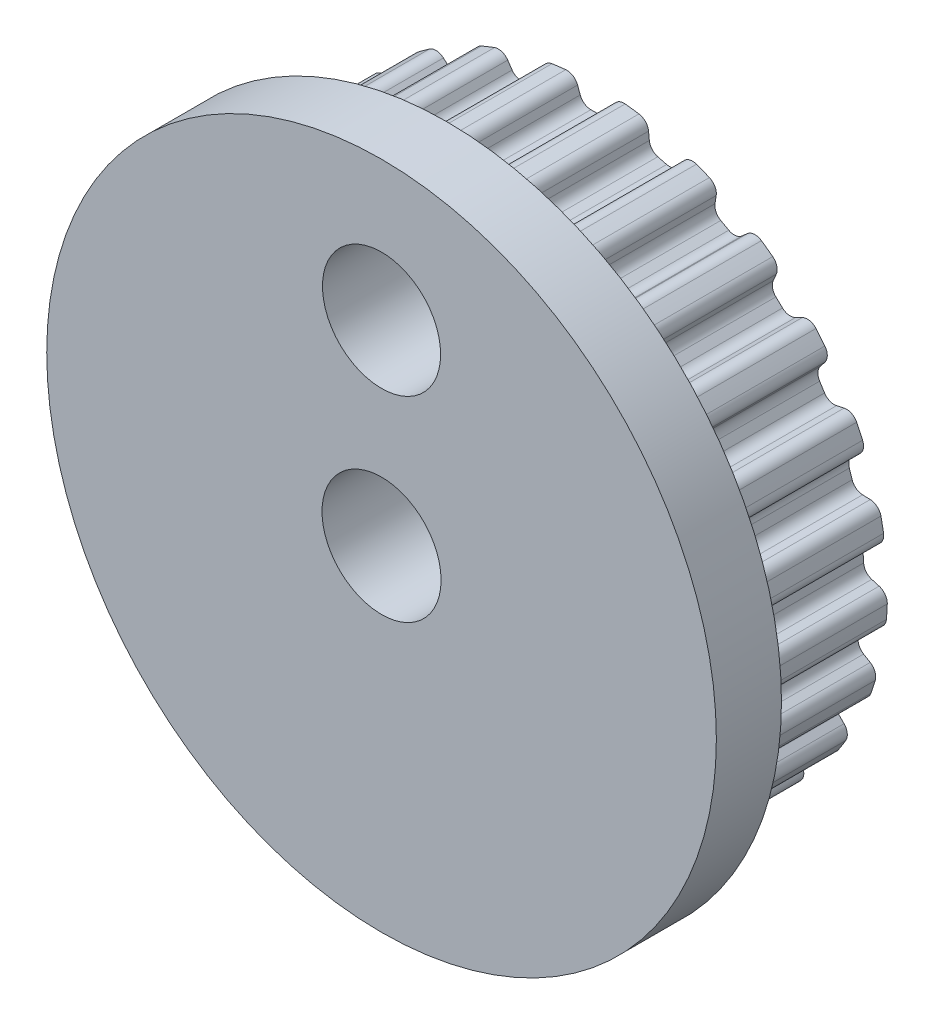
from build123d import *

# Parameters (mm, degrees)
BOSS_EXTRUDE1_DEPTH = 4.000000001
SKETCH2_R           = 9
BOSS_EXTRUDE2_DEPTH = 1.75
SKETCH4_W           = 4.5
SKETCH4_H           = 4.5
BOSS_EXTRUDE3_DEPTH = 1.75
SKETCH3_R           = 1.6
CUT_EXTRUDE2_DEPTH  = 8.500000001
SKETCH5_R           = 1.5875
CUT_EXTRUDE3_DEPTH  = 8.500000001


with BuildPart() as part:
    # Sketch1 → Boss-Extrude1 (new body)
    with BuildSketch(Plane(origin=(0, 0, -5.299999992), x_dir=(-1, 0, 0), z_dir=(0, 0, -1))):
        with BuildLine():
            Line((-2.770498963, -6.663011251), (-2.541538281, -6.753663208))
            ThreePointArc((-2.541538281, -6.753663208), (-2.399281022, -6.869272551), (-2.349061487, -7.04556959))
            Line((-2.349061487, -7.04556959), (-2.354850369, -7.252814955))
            ThreePointArc((-2.354850369, -7.252814955), (-2.295763451, -7.44184279), (-2.13298896, -7.55465791))
            ThreePointArc((-2.13298896, -7.55465791), (-1.9522156, -7.60337769), (-1.770331764, -7.647772452))
            ThreePointArc((-1.770331764, -7.647772452), (-1.573342284, -7.627329016), (-1.430499165, -7.490147994))
            Line((-1.430499165, -7.490147994), (-1.335730789, -7.305748684))
            ThreePointArc((-1.335730789, -7.305748684), (-1.206791332, -7.175451857), (-1.026435123, -7.142675578))
            Line((-1.026435123, -7.142675578), (-0.782123427, -7.173539321))
            ThreePointArc((-0.782123427, -7.173539321), (-0.615584572, -7.250138629), (-0.523099481, -7.408407869))
            Line((-0.523099481, -7.408407869), (-0.477166643, -7.610581923))
            ThreePointArc((-0.477166643, -7.610581923), (-0.372926733, -7.778976773), (-0.187210126, -7.847767225))
            ThreePointArc((-0.187210126, -7.847767225), (1.8e-08, -7.849999876), (0.187210163, -7.847767225))
            ThreePointArc((0.187210163, -7.847767225), (0.372926769, -7.778976773), (0.477166678, -7.610581924))
            Line((0.477166678, -7.610581924), (0.523099513, -7.408407881))
            ThreePointArc((0.523099513, -7.408407881), (0.615584602, -7.250138644), (0.782123452, -7.173539334))
            Line((0.782123452, -7.173539334), (1.026435157, -7.142675586))
            ThreePointArc((1.026435157, -7.142675586), (1.206791369, -7.175451863), (1.33573083, -7.305748691))
            Line((1.33573083, -7.305748691), (1.430499202, -7.490147994))
            ThreePointArc((1.430499202, -7.490147994), (1.573342321, -7.627329016), (1.770331801, -7.647772452))
            ThreePointArc((1.770331801, -7.647772452), (1.952215637, -7.60337769), (2.132988997, -7.55465791))
            ThreePointArc((2.132988997, -7.55465791), (2.295763494, -7.441842782), (2.354850406, -7.252814935))
            Line((2.354850406, -7.252814935), (2.349061514, -7.045569606))
            ThreePointArc((2.349061514, -7.045569606), (2.399281043, -6.869272556), (2.541538305, -6.753663204))
            Line((2.541538305, -6.753663204), (2.770498989, -6.663011244))
            ThreePointArc((2.770498989, -6.663011244), (2.953340111, -6.64990502), (3.11063221, -6.744042389))
            Line((3.11063221, -6.744042389), (3.248281539, -6.899080544))
            ThreePointArc((3.248281539, -6.899080544), (3.42075251, -6.996428125), (3.616637274, -6.967240001))
            ThreePointArc((3.616637274, -6.967240001), (3.781766365, -6.879007311), (3.94474428, -6.786861647))
            ThreePointArc((3.94474428, -6.786861647), (4.074348937, -6.637110438), (4.084570207, -6.439326927))
            Line((4.084570207, -6.439326927), (4.027423359, -6.240032231))
            ThreePointArc((4.027423359, -6.240032231), (4.032221853, -6.056784784), (4.141258967, -5.909429568))
            Line((4.141258967, -5.909429568), (4.340482222, -5.76468539))
            ThreePointArc((4.340482222, -5.76468539), (4.514319692, -5.706520185), (4.690081199, -5.758583127))
            Line((4.690081199, -5.758583127), (4.861962355, -5.874518455))
            ThreePointArc((4.861962355, -5.874518455), (5.053224205, -5.925915922), (5.235696117, -5.848930236))
            ThreePointArc((5.235696117, -5.848930236), (5.373694804, -5.722403597), (5.50863678, -5.592621893))
            ThreePointArc((5.50863678, -5.592621893), (5.596928058, -5.415344021), (5.557641445, -5.221232311))
            Line((5.557641445, -5.221232311), (5.452727407, -5.042410696))
            ThreePointArc((5.452727407, -5.042410696), (5.411803358, -4.863726966), (5.480769122, -4.693884755))
            Line((5.480769122, -4.693884755), (5.637737001, -4.504143178))
            ThreePointArc((5.637737001, -4.504143178), (5.791647936, -4.404573728), (5.974835084, -4.411290898))
            Line((5.974835084, -4.411290898), (6.170148257, -4.480838795))
            ThreePointArc((6.170148257, -4.480838795), (6.368183279, -4.483056618), (6.525776925, -4.363110665))
            ThreePointArc((6.525776925, -4.363110665), (6.627974228, -4.206240225), (6.726401351, -4.046977156))
            ThreePointArc((6.726401351, -4.046977156), (6.767831585, -3.853311658), (6.681505632, -3.675068511))
            Line((6.681505632, -3.675068511), (6.535416505, -3.527955909))
            ThreePointArc((6.535416505, -3.527955909), (6.451341341, -3.365063263), (6.475902375, -3.183405886))
            Line((6.475902375, -3.183405886), (6.580751989, -2.960589078))
            ThreePointArc((6.580751989, -2.960589078), (6.705065617, -2.825871679), (6.884168106, -2.78682102))
            Line((6.884168106, -2.78682102), (7.090641024, -2.805611531))
            ThreePointArc((7.090641024, -2.805611531), (7.283005966, -2.758510368), (7.405819176, -2.603140787))
            ThreePointArc((7.405819176, -2.603140787), (7.46579367, -2.425783284), (7.52152141, -2.247045927))
            ThreePointArc((7.52152141, -2.247045927), (7.513487384, -2.049161499), (7.385546242, -1.897986579))
            Line((7.385546242, -1.897986579), (7.207461372, -1.791826697))
            ThreePointArc((7.207461372, -1.791826697), (7.085517816, -1.654960251), (7.06413088, -1.472901871))
            Line((7.06413088, -1.472901871), (7.110274201, -1.231010202))
            ThreePointArc((7.110274201, -1.231010202), (7.197179435, -1.069609688), (7.360943563, -0.987244916))
            Line((7.360943563, -0.987244916), (7.565602753, -0.95409736))
            ThreePointArc((7.565602753, -0.95409736), (7.740210608, -0.86063675), (7.820526569, -0.679605993))
            ThreePointArc((7.820526569, -0.679605993), (7.834509837, -0.492905448), (7.844036614, -0.305924525))
            ThreePointArc((7.844036614, -0.305924525), (7.78704314, -0.116254991), (7.625525841, -0.001647178))
            Line((7.625525841, -0.001647178), (7.426634918, 0.056889606))
            ThreePointArc((7.426634918, 0.056889606), (7.274485151, 0.15913001), (7.208494045, 0.330149967))
            Line((7.208494045, 0.330149967), (7.193031666, 0.575917525))
            ThreePointArc((7.193031666, 0.575917525), (7.237067931, 0.753859804), (7.375203825, 0.874363422))
            Line((7.375203825, 0.874363422), (7.565189822, 0.957366261))
            ThreePointArc((7.565189822, 0.957366261), (7.711069345, 1.091313843), (7.743841513, 1.286630957))
            ThreePointArc((7.743841513, 1.286630957), (7.710954935, 1.470943449), (7.673682148, 1.654419227))
            ThreePointArc((7.673682148, 1.654419227), (7.571310327, 1.82395625), (7.386365577, 1.894795725))
            Line((7.386365577, 1.894795725), (7.179165715, 1.902031296))
            ThreePointArc((7.179165715, 1.902031296), (7.006369859, 1.963221511), (6.899921047, 2.112457233))
            Line((6.899921047, 2.112457233), (6.823824527, 2.346658216))
            ThreePointArc((6.823824527, 2.346658216), (6.822224861, 2.529961496), (6.926052937, 2.681032281))
            Line((6.926052937, 2.681032281), (7.089428199, 2.808675019))
            ThreePointArc((7.089428199, 2.808675019), (7.197413244, 2.974693155), (7.180582424, 3.172024133))
            ThreePointArc((7.180582424, 3.172024133), (7.10289238, 3.342367562), (7.02116201, 3.510809758))
            ThreePointArc((7.02116201, 3.510809758), (6.879844249, 3.649561624), (6.683092823, 3.67218166))
            Line((6.683092823, 3.67218166), (6.480603082, 3.627661399))
            ThreePointArc((6.480603082, 3.627661399), (6.298018541, 3.643956633), (6.157800604, 3.762031099))
            Line((6.157800604, 3.762031099), (6.025851382, 3.969949803))
            ThreePointArc((6.025851382, 3.969949803), (5.978716304, 4.147096461), (6.041712663, 4.319242076))
            Line((6.041712663, 4.319242076), (6.168211718, 4.483504424))
            ThreePointArc((6.168211718, 4.483504424), (6.231517191, 4.671161588), (6.166140924, 4.858107403))
            ThreePointArc((6.166140924, 4.858107403), (6.048528974, 5.003778443), (5.927476451, 5.146603192))
            ThreePointArc((5.927476451, 5.146603192), (5.756092274, 5.245851614), (5.559896791, 5.218830927))
            Line((5.559896791, 5.218830927), (5.374840317, 5.125352196))
            ThreePointArc((5.374840317, 5.125352196), (5.193939557, 5.095728573), (5.028762915, 5.175222731))
            Line((5.028762915, 5.175222731), (4.849251859, 5.343794843))
            ThreePointArc((4.849251859, 5.343794843), (4.759543042, 5.50365408), (4.777749369, 5.686057966))
            Line((4.777749369, 5.686057966), (4.859423838, 5.876618788))
            ThreePointArc((4.859423838, 5.876618788), (4.874072, 6.074123776), (4.764258119, 6.238937914))
            ThreePointArc((4.764258119, 6.238937914), (4.614114251, 6.350783528), (4.461345743, 6.459016637))
            ThreePointArc((4.461345743, 6.459016637), (4.270663826, 6.512525475), (4.087351951, 6.437561846))
            Line((4.087351951, 6.437561846), (3.931356637, 6.300998273))
            ThreePointArc((3.931356637, 6.300998273), (3.763506296, 6.227317127), (3.583749576, 6.263236065))
            Line((3.583749576, 6.263236065), (3.367956, 6.381869588))
            ThreePointArc((3.367956, 6.381869588), (3.241310171, 6.514396877), (3.213582509, 6.69559794))
            Line((3.213582509, 6.69559794), (3.245300476, 6.900483573))
            ThreePointArc((3.245300476, 6.900483573), (3.210370947, 7.095426422), (3.063019466, 7.227753016))
            ThreePointArc((3.063019466, 7.227753016), (2.889777761, 7.298745536), (2.714892269, 7.365586324))
            ThreePointArc((2.714892269, 7.365586324), (2.516893872, 7.369993419), (2.357983776, 7.251797104))
            Line((2.357983776, 7.251797104), (2.240851316, 7.080729469))
            ThreePointArc((2.240851316, 7.080729469), (2.096598059, 6.967620471), (1.913556053, 6.957707268))
            Line((1.913556053, 6.957707268), (1.675039076, 7.018948014))
            ThreePointArc((1.675039076, 7.018948014), (1.51941385, 7.115816183), (1.447494432, 7.284428907))
            Line((1.447494432, 7.284428907), (1.427262951, 7.490765576))
            ThreePointArc((1.427262951, 7.490765576), (1.344950483, 7.670897333), (1.169320022, 7.762421829))
            ThreePointArc((1.169320022, 7.762421829), (0.983865903, 7.788100529), (0.797852133, 7.809349137))
            ThreePointArc((0.797852133, 7.809349137), (0.604978216, 7.764377573), (0.480454802, 7.610375273))
            Line((0.480454802, 7.610375273), (0.409545077, 7.415552396))
            ThreePointArc((0.409545077, 7.415552396), (0.297952865, 7.270122591), (0.123126767, 7.215000134))
            Line((0.123126767, 7.215000134), (-0.12312673, 7.215000134))
            ThreePointArc((-0.12312673, 7.215000134), (-0.297952827, 7.270122591), (-0.409545038, 7.415552395))
            Line((-0.409545038, 7.415552395), (-0.480454763, 7.610375271))
            ThreePointArc((-0.480454763, 7.610375271), (-0.604978178, 7.764377573), (-0.797852096, 7.809349137))
            ThreePointArc((-0.797852096, 7.809349137), (-0.983865866, 7.788100529), (-1.169319985, 7.762421829))
            ThreePointArc((-1.169319985, 7.762421829), (-1.344950446, 7.670897333), (-1.427262914, 7.490765576))
            Line((-1.427262914, 7.490765576), (-1.447494396, 7.284428898))
            ThreePointArc((-1.447494396, 7.284428898), (-1.519413814, 7.115816175), (-1.67503904, 7.018948005))
            Line((-1.67503904, 7.018948005), (-1.913556012, 6.957707261))
            ThreePointArc((-1.913556012, 6.957707261), (-2.096598018, 6.967620464), (-2.240851274, 7.080729462))
            Line((-2.240851274, 7.080729462), (-2.357983739, 7.251797104))
            ThreePointArc((-2.357983739, 7.251797104), (-2.516893836, 7.369993419), (-2.714892233, 7.365586324))
            ThreePointArc((-2.714892233, 7.365586324), (-2.889777725, 7.298745536), (-3.063019429, 7.227753016))
            ThreePointArc((-3.063019429, 7.227753016), (-3.210370911, 7.095426422), (-3.24530044, 6.900483573))
            Line((-3.24530044, 6.900483573), (-3.21358247, 6.695597928))
            ThreePointArc((-3.21358247, 6.695597928), (-3.241310132, 6.514396865), (-3.367955962, 6.381869576))
            Line((-3.367955962, 6.381869576), (-3.58374953, 6.263236057))
            ThreePointArc((-3.58374953, 6.263236057), (-3.76350625, 6.227317119), (-3.931356591, 6.300998266))
            Line((-3.931356591, 6.300998266), (-4.087351915, 6.437561846))
            ThreePointArc((-4.087351915, 6.437561846), (-4.27066379, 6.512525475), (-4.461345707, 6.459016637))
            ThreePointArc((-4.461345707, 6.459016637), (-4.614114214, 6.350783528), (-4.764258082, 6.238937914))
            ThreePointArc((-4.764258082, 6.238937914), (-4.874071964, 6.074123776), (-4.859423801, 5.876618788))
            Line((-4.859423801, 5.876618788), (-4.77774934, 5.686057982))
            ThreePointArc((-4.77774934, 5.686057982), (-4.759543013, 5.503654097), (-4.849251829, 5.343794859))
            Line((-4.849251829, 5.343794859), (-5.028762894, 5.17522274))
            ThreePointArc((-5.028762894, 5.17522274), (-5.193939536, 5.095728582), (-5.374840296, 5.125352204))
            Line((-5.374840296, 5.125352204), (-5.559896754, 5.218830927))
            ThreePointArc((-5.559896754, 5.218830927), (-5.756092237, 5.245851614), (-5.927476414, 5.146603192))
            ThreePointArc((-5.927476414, 5.146603192), (-6.048528938, 5.003778443), (-6.166140887, 4.858107403))
            ThreePointArc((-6.166140887, 4.858107403), (-6.231517154, 4.671161588), (-6.168211682, 4.483504424))
            Line((-6.168211682, 4.483504424), (-6.04171263, 4.31924208))
            ThreePointArc((-6.04171263, 4.31924208), (-5.978716271, 4.147096465), (-6.025851349, 3.969949807))
            Line((-6.025851349, 3.969949807), (-6.157800573, 3.7620311))
            ThreePointArc((-6.157800573, 3.7620311), (-6.29801851, 3.643956634), (-6.480603051, 3.6276614))
            Line((-6.480603051, 3.6276614), (-6.683092787, 3.67218166))
            ThreePointArc((-6.683092787, 3.67218166), (-6.879844213, 3.649561624), (-7.021161973, 3.510809758))
            ThreePointArc((-7.021161973, 3.510809758), (-7.102892344, 3.342367562), (-7.180582387, 3.172024133))
            ThreePointArc((-7.180582387, 3.172024133), (-7.197413207, 2.974693155), (-7.089428162, 2.808675019))
            Line((-7.089428162, 2.808675019), (-6.926052897, 2.681032278))
            ThreePointArc((-6.926052897, 2.681032278), (-6.822224821, 2.529961494), (-6.823824488, 2.346658214))
            Line((-6.823824488, 2.346658214), (-6.899921006, 2.112457233))
            ThreePointArc((-6.899921006, 2.112457233), (-7.006369819, 1.963221511), (-7.179165675, 1.902031296))
            Line((-7.179165675, 1.902031296), (-7.386365541, 1.894795725))
            ThreePointArc((-7.386365541, 1.894795725), (-7.571310291, 1.82395625), (-7.673682111, 1.654419227))
            ThreePointArc((-7.673682111, 1.654419227), (-7.710954911, 1.470943384), (-7.743841498, 1.286630826))
            ThreePointArc((-7.743841498, 1.286630826), (-7.711069328, 1.091313715), (-7.565189806, 0.957366136))
            Line((-7.565189806, 0.957366136), (-7.375203809, 0.874363296))
            ThreePointArc((-7.375203809, 0.874363296), (-7.237067915, 0.753859678), (-7.19303165, 0.5759174))
            Line((-7.19303165, 0.5759174), (-7.20849403, 0.330149843))
            ThreePointArc((-7.20849403, 0.330149843), (-7.274485135, 0.159129886), (-7.426634903, 0.056889483))
            Line((-7.426634903, 0.056889483), (-7.6255258, -0.001647294))
            ThreePointArc((-7.6255258, -0.001647294), (-7.7870431, -0.116255109), (-7.844036572, -0.305924646))
            ThreePointArc((-7.844036572, -0.305924646), (-7.834509796, -0.492905509), (-7.820526532, -0.679605993))
            ThreePointArc((-7.820526532, -0.679605993), (-7.740210572, -0.86063675), (-7.565602716, -0.95409736))
            Line((-7.565602716, -0.95409736), (-7.360943526, -0.987244916))
            ThreePointArc((-7.360943526, -0.987244916), (-7.197179397, -1.069609688), (-7.110274163, -1.231010202))
            Line((-7.110274163, -1.231010202), (-7.064130842, -1.47290187))
            ThreePointArc((-7.064130842, -1.47290187), (-7.085517778, -1.654960251), (-7.207461334, -1.791826697))
            Line((-7.207461334, -1.791826697), (-7.385546205, -1.897986579))
            ThreePointArc((-7.385546205, -1.897986579), (-7.513487347, -2.049161499), (-7.521521373, -2.247045927))
            ThreePointArc((-7.521521373, -2.247045927), (-7.465793634, -2.425783284), (-7.405819139, -2.603140787))
            ThreePointArc((-7.405819139, -2.603140787), (-7.28300593, -2.758510368), (-7.090640987, -2.805611531))
            Line((-7.090640987, -2.805611531), (-6.884168079, -2.786821021))
            ThreePointArc((-6.884168079, -2.786821021), (-6.705065589, -2.82587168), (-6.580751962, -2.960589079))
            Line((-6.580751962, -2.960589079), (-6.475902344, -3.183405892))
            ThreePointArc((-6.475902344, -3.183405892), (-6.451341311, -3.36506327), (-6.535416475, -3.527955915))
            Line((-6.535416475, -3.527955915), (-6.681505595, -3.675068511))
            ThreePointArc((-6.681505595, -3.675068511), (-6.767831549, -3.853311658), (-6.726401314, -4.046977156))
            ThreePointArc((-6.726401314, -4.046977156), (-6.627974191, -4.206240225), (-6.525776888, -4.363110665))
            ThreePointArc((-6.525776888, -4.363110665), (-6.368183242, -4.483056618), (-6.17014822, -4.480838795))
            Line((-6.17014822, -4.480838795), (-5.974835047, -4.411290898))
            ThreePointArc((-5.974835047, -4.411290898), (-5.791647899, -4.404573728), (-5.637736963, -4.504143178))
            Line((-5.637736963, -4.504143178), (-5.480769085, -4.693884754))
            ThreePointArc((-5.480769085, -4.693884754), (-5.411803321, -4.863726965), (-5.45272737, -5.042410695))
            Line((-5.45272737, -5.042410695), (-5.557641409, -5.221232311))
            ThreePointArc((-5.557641409, -5.221232311), (-5.596928022, -5.415344021), (-5.508636743, -5.592621893))
            ThreePointArc((-5.508636743, -5.592621893), (-5.373694767, -5.722403597), (-5.235696081, -5.848930236))
            ThreePointArc((-5.235696081, -5.848930236), (-5.053224168, -5.925915922), (-4.861962318, -5.874518455))
            Line((-4.861962318, -5.874518455), (-4.690081172, -5.758583134))
            ThreePointArc((-4.690081172, -5.758583134), (-4.514319665, -5.706520192), (-4.340482195, -5.764685397))
            Line((-4.340482195, -5.764685397), (-4.141258934, -5.909429579))
            ThreePointArc((-4.141258934, -5.909429579), (-4.032221819, -6.056784796), (-4.027423326, -6.240032243))
            Line((-4.027423326, -6.240032243), (-4.08457017, -6.439326927))
            ThreePointArc((-4.08457017, -6.439326927), (-4.0743489, -6.637110438), (-3.944744243, -6.786861647))
            ThreePointArc((-3.944744243, -6.786861647), (-3.781766328, -6.879007311), (-3.616637238, -6.967240001))
            ThreePointArc((-3.616637238, -6.967240001), (-3.420752473, -6.996428125), (-3.248281502, -6.899080544))
            Line((-3.248281502, -6.899080544), (-3.110632181, -6.744042398))
            ThreePointArc((-3.110632181, -6.744042398), (-2.953340083, -6.649905029), (-2.770498963, -6.663011251))
        make_face()
    extrude(amount=-BOSS_EXTRUDE1_DEPTH)

    # Sketch2 → Boss-Extrude2 (add)
    with BuildSketch(Plane.XY.offset(-1.299999991)):
        Circle(SKETCH2_R)
    extrude(amount=BOSS_EXTRUDE2_DEPTH)

    # Sketch4 → Boss-Extrude3 (add)
    with BuildSketch(Plane(origin=(0, 0, -5.299999992), x_dir=(-1, 0, 0), z_dir=(0, 0, -1))):
        Rectangle(SKETCH4_W, SKETCH4_H)
    extrude(amount=BOSS_EXTRUDE3_DEPTH)

    # Sketch3 → Cut-Extrude2 (cut, through all)
    with BuildSketch(Plane.XY.offset(0.450000009)):
        Circle(SKETCH3_R)
    extrude(amount=-CUT_EXTRUDE2_DEPTH, mode=Mode.SUBTRACT)

    # Sketch5 → Cut-Extrude3 (cut, through all)
    with BuildSketch(Plane.XY.offset(0.450000009)):
        with Locations((0, 5.25)):
            Circle(SKETCH5_R)
    extrude(amount=-CUT_EXTRUDE3_DEPTH, mode=Mode.SUBTRACT)


solid = part.part
